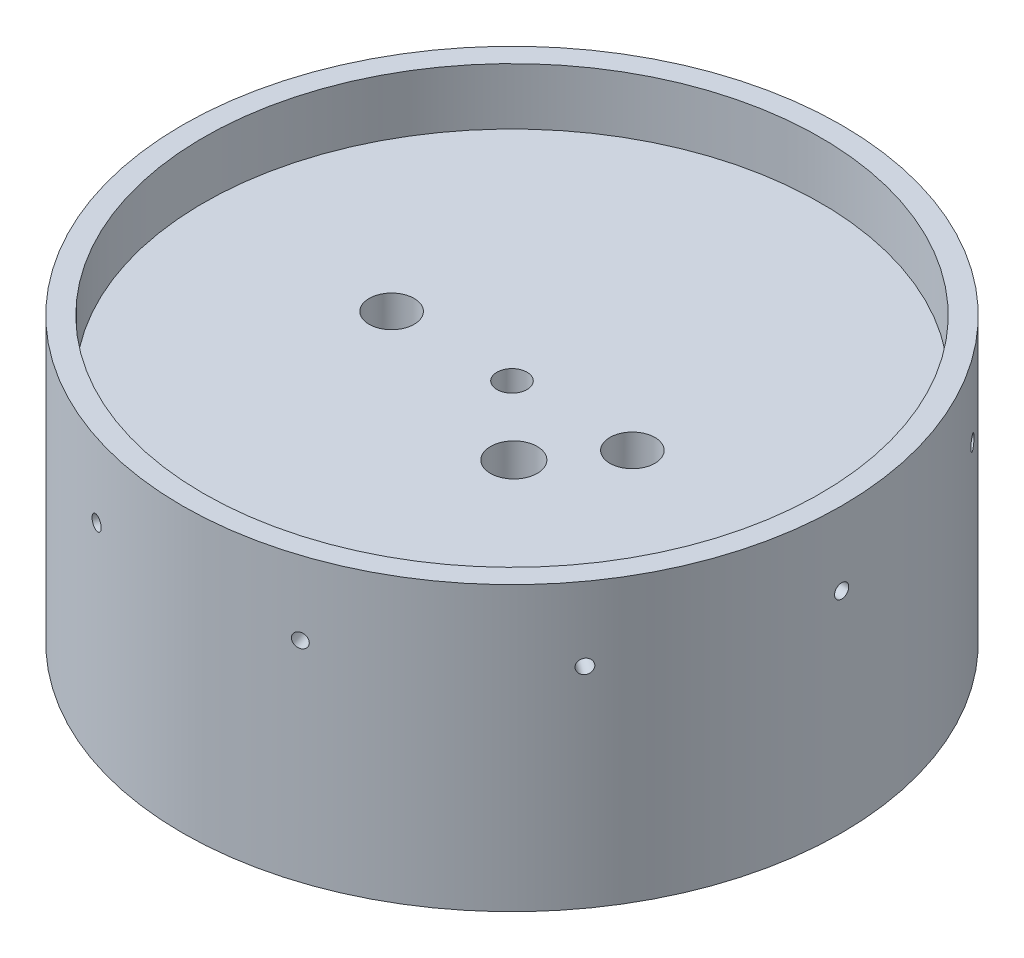
from build123d import *

# Parameters (mm, degrees)
F_1_4_CLEARANCE_HOLE1_D = 6.7564
CIRPATTERN2_COUNT       = 10
F_3_8_CLEARANCE_HOLE1_D = 10.0838
SKETCH12_R              = 5.23875
CUT_EXTRUDE1_DEPTH      = 7.62


with BuildPart() as part:
    # Sketch1 → Revolve1 (revolve)
    with BuildSketch(Plane.XY):
        Polygon((0, -12.7), (-69.1515, -12.7), (-69.1515, 0), (-73.914, 0), (-73.914, -63.5), (-69.1515, -63.5), (-69.1515, -20.32), (0, -20.32), align=None)
    revolve(axis=Axis((0, 0, 0), (0, -1, 0)))

    # 1/4 Clearance Hole1 (through all)
    with Locations(Plane(origin=(0, -12.7, 0), x_dir=(1, 0, 0), z_dir=(0, 1, 0))):
        with Locations((0, 0)):
            Hole(F_1_4_CLEARANCE_HOLE1_D / 2)

    # Sketch7 → 1/8 (0.1250) Dowel Hole1 (revolve, cut)
    with BuildSketch(Plane(origin=(-73.914, -16.51, 0), x_dir=(0, 0, 1), z_dir=(0, 1, 0))):
        Polygon((0, 0), (0, 26.353866233), (1.5875, 25.4), (1.5875, 0), align=None)
    f_1_8_0_1250_dowel_hole1 = revolve(axis=Axis((-80.264, -16.51, 0), (1, 0, 0)), mode=Mode.SUBTRACT)

    # CirPattern2: 1/8 (0.1250) Dowel Hole1 ×10 about axis
    cirpattern2_axis = Axis((0, 0, 0), (0, 1, 0))
    for i in range(1, CIRPATTERN2_COUNT):
        add(f_1_8_0_1250_dowel_hole1.rotate(cirpattern2_axis, i * 360 / CIRPATTERN2_COUNT), mode=Mode.SUBTRACT)

    # 3/8 Clearance Hole1 (through all)
    with Locations(Plane(origin=(-26.9875, -12.7, 0), x_dir=(0, 0, 1), z_dir=(0, 1, 0))):
        with Locations((0, 0), (0, 53.975)):
            Hole(F_3_8_CLEARANCE_HOLE1_D / 2)

    # Sketch12 → Cut-Extrude1 (cut)
    with BuildSketch(Plane.XZ.offset(20.32)):
        with Locations((15.5575, 15.1384)):
            Circle(SKETCH12_R)
    extrude(amount=-CUT_EXTRUDE1_DEPTH, mode=Mode.SUBTRACT)


solid = part.part
